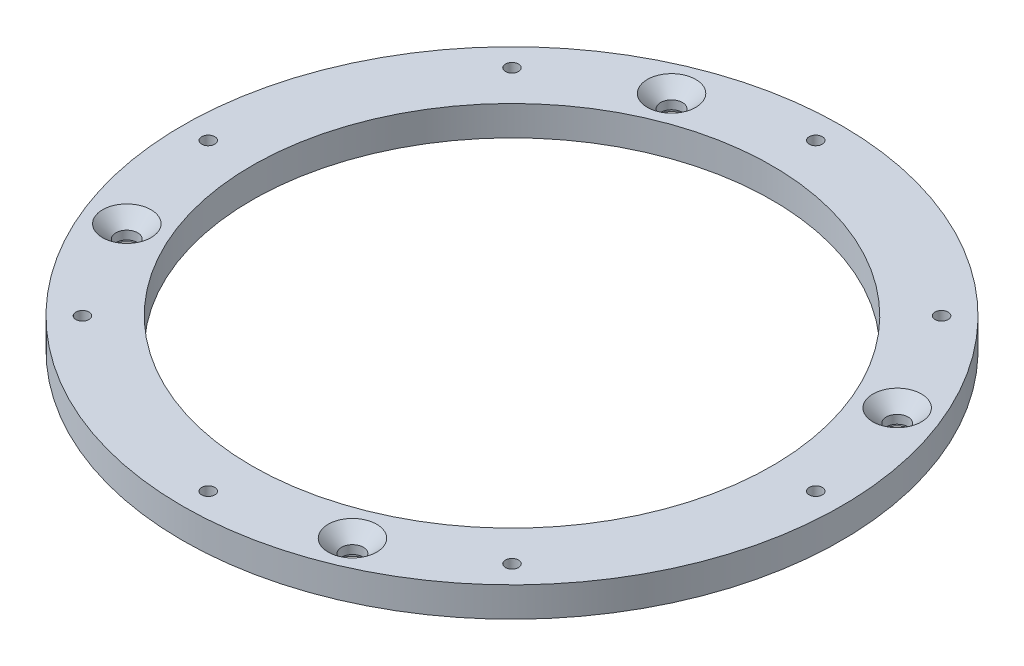
from build123d import *

# Parameters (mm, degrees)
SKETCH1_R                                            = 166
SKETCH1_R_2                                          = 131
BOSS_EXTRUDE1_DEPTH                                  = 15
M6_CLEARANCE_HOLE1_D                                 = 6.6
CIRPATTERN1_COUNT                                    = 8
SKETCH4_R                                            = 10
CUT_EXTRUDE1_DEPTH                                   = 4
CSK_FOR_M10_HEX_SOCKET_COUNTERSUNK_CAP_S_D           = 11
CSK_FOR_M10_HEX_SOCKET_COUNTERSUNK_CAP_S_CSINK_D     = 24.4
CSK_FOR_M10_HEX_SOCKET_COUNTERSUNK_CAP_S_CSINK_ANGLE = 90
CIRPATTERN2_COUNT                                    = 4


with BuildPart() as part:
    # Sketch1 → Boss-Extrude1 (new body)
    with BuildSketch(Plane(origin=(0, 0, 0), x_dir=(1, 0, 0), z_dir=(0, 1, 0))):
        Circle(SKETCH1_R)
        Circle(SKETCH1_R_2, mode=Mode.SUBTRACT)
    extrude(amount=BOSS_EXTRUDE1_DEPTH)

    # M6 Clearance Hole1 (through all)
    with Locations(Plane(origin=(0, 0, 0), x_dir=(-1, 0, 0), z_dir=(0, -1, 0))):
        with Locations((0, 153)):
            m6_clearance_hole1 = Hole(M6_CLEARANCE_HOLE1_D / 2)

    # CirPattern1: M6 Clearance Hole1 ×8 about axis
    cirpattern1_axis = Axis((0, 0, 0), (0, 1, 0))
    for i in range(1, CIRPATTERN1_COUNT):
        add(m6_clearance_hole1.rotate(cirpattern1_axis, i * 360 / CIRPATTERN1_COUNT), mode=Mode.SUBTRACT)

    # Sketch4 → Cut-Extrude1 (cut)
    with BuildSketch(Plane.XZ):
        with Locations((-137.196110578, 56.828489706)):
            Circle(SKETCH4_R)
    cut_extrude1 = extrude(amount=-CUT_EXTRUDE1_DEPTH, mode=Mode.SUBTRACT)

    # CSK for M10 Hex Socket Countersunk Cap Screw1 (through all)
    with Locations(Plane(origin=(0, 15, 0), x_dir=(1, 0, 0), z_dir=(0, 1, 0))):
        with Locations((-137.196110578, -56.828489706)):
            csk_for_m10_hex_socket_countersunk_cap_s = CounterSinkHole(CSK_FOR_M10_HEX_SOCKET_COUNTERSUNK_CAP_S_D / 2, CSK_FOR_M10_HEX_SOCKET_COUNTERSUNK_CAP_S_CSINK_D / 2, counter_sink_angle=CSK_FOR_M10_HEX_SOCKET_COUNTERSUNK_CAP_S_CSINK_ANGLE)

    # CirPattern2: Cut-Extrude1, CSK for M10 Hex Socket Countersunk Cap Screw1 ×4 about axis
    cirpattern2_axis = Axis((0, 0, 0), (0, 1, 0))
    for i in range(1, CIRPATTERN2_COUNT):
        add(cut_extrude1.rotate(cirpattern2_axis, i * 360 / CIRPATTERN2_COUNT), mode=Mode.SUBTRACT)
        add(csk_for_m10_hex_socket_countersunk_cap_s.rotate(cirpattern2_axis, i * 360 / CIRPATTERN2_COUNT), mode=Mode.SUBTRACT)


solid = part.part
